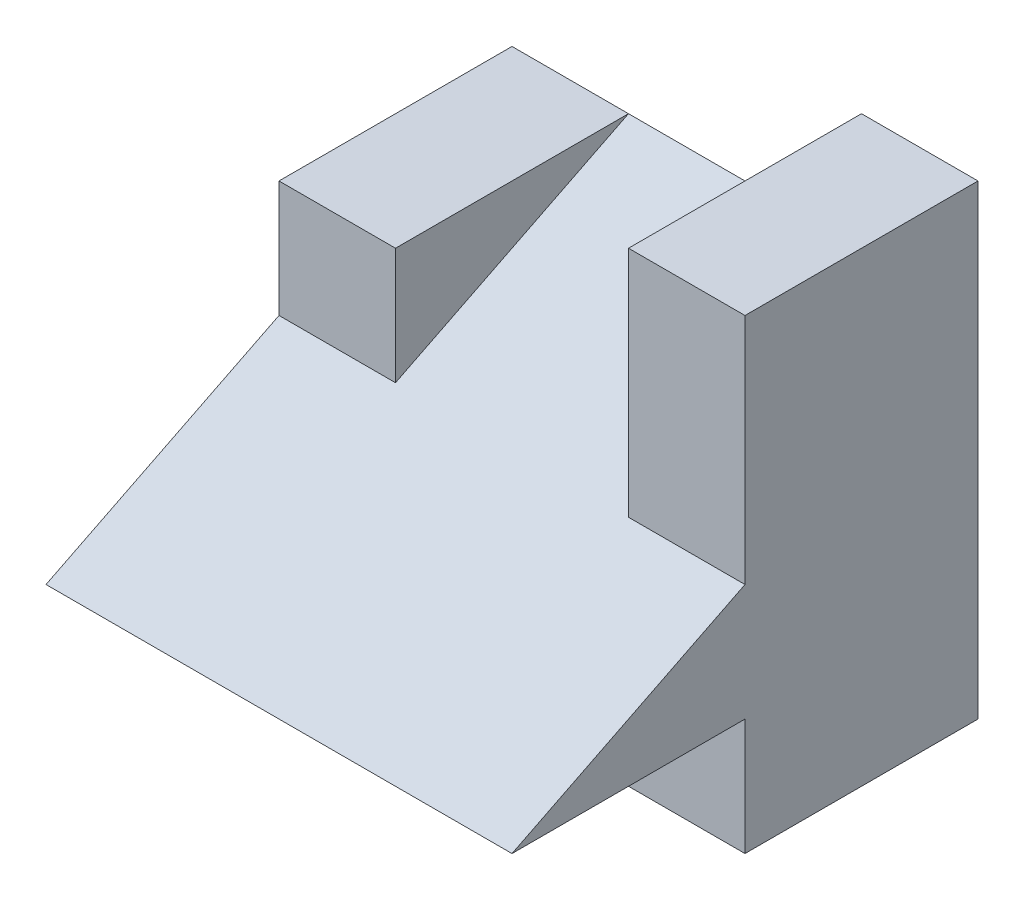
from build123d import *

# Parameters (mm, degrees)
SKETCH2_W           = 4
SKETCH2_H           = 4
BOSS_EXTRUDE1_DEPTH = 4
SKETCH3_W           = 2
SKETCH3_H           = 1
CUT_EXTRUDE1_DEPTH  = 14
SKETCH4_W           = 2
SKETCH4_H           = 1
CUT_EXTRUDE2_DEPTH  = 3
CUT_EXTRUDE3_DEPTH  = 2


with BuildPart() as part:
    # Sketch2 → Boss-Extrude1 (new body)
    with BuildSketch(Plane(origin=(0, 0, 0), x_dir=(1, 0, 0), z_dir=(0, 1, 0))):
        Rectangle(SKETCH2_W, SKETCH2_H)
    extrude(amount=BOSS_EXTRUDE1_DEPTH)

    # Sketch3 → Cut-Extrude1 (cut)
    with BuildSketch(Plane.ZY.offset(2)):
        Polygon((0, 4), (0, 2), (2, 1), (2, 2), (2, 4), align=None)
        with Locations((1, 0.5)):
            Rectangle(SKETCH3_W, SKETCH3_H)
    extrude(amount=-CUT_EXTRUDE1_DEPTH, mode=Mode.SUBTRACT)

    # Sketch4 → Cut-Extrude2 (cut)
    with BuildSketch(Plane.ZY.offset(2)):
        with Locations((-1, 3.5)):
            Rectangle(SKETCH4_W, SKETCH4_H)
    extrude(amount=-CUT_EXTRUDE2_DEPTH, mode=Mode.SUBTRACT)

    # Sketch6 → Cut-Extrude3 (cut)
    with BuildSketch(Plane.ZY.offset(-1)):
        Polygon((-2, 3), (0, 2), (0, 3), align=None)
    extrude(amount=CUT_EXTRUDE3_DEPTH, mode=Mode.SUBTRACT)


solid = part.part
